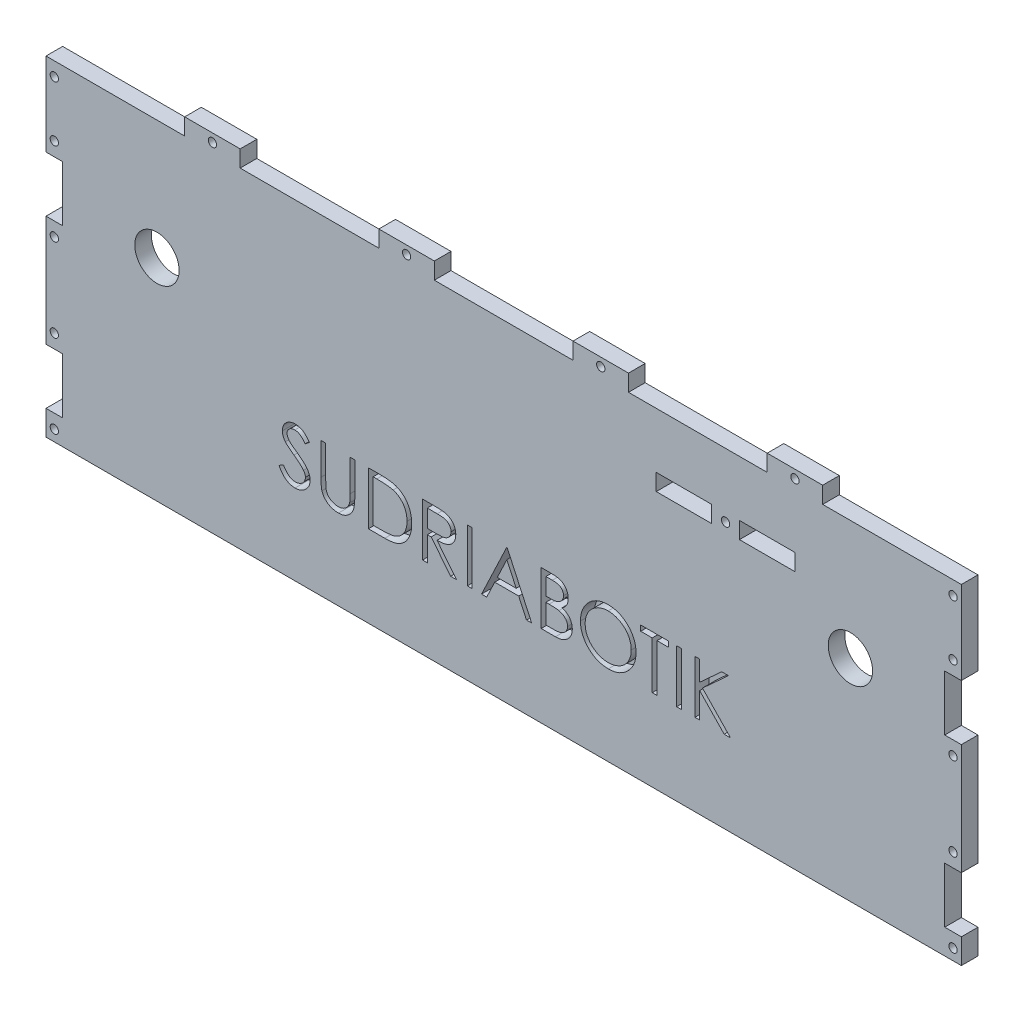
from build123d import *

# Parameters (mm, degrees)
ESQUISSE1_W             = 330
ESQUISSE1_H             = 238
ESQUISSE1_R             = 8
ESQUISSE1_W_2           = 15
ESQUISSE1_H_2           = 6
ESQUISSE1_W_3           = 20
BOSS_EXTRU_1_DEPTH      = 6
ESQUISSE2_W             = 20
ESQUISSE2_H             = 6
BOSS_EXTRU_2_DEPTH      = 6
ESQUISSE3_W             = 6
ESQUISSE3_H             = 20
ESQUISSE3_W_2           = 12
ESQUISSE3_H_2           = 10
ENL_V_MAT_EXTRU_1_DEPTH = 6
ESQUISSE4_R             = 1.5
ENL_V_MAT_EXTRU_2_DEPTH = 6
ESQUISSE5_W             = 423.604058921
ESQUISSE5_H             = 150.356061945
ENL_V_MAT_EXTRU_3_DEPTH = 6
ESQUISSE6_W             = 1.709615384
ESQUISSE6_H             = 19.05
ESQUISSE6_W_2           = 1.709615385
ENL_V_MAT_EXTRU_4_DEPTH = 5


with BuildPart() as part:
    # Esquisse1 → Boss.-Extru.1 (new body)
    with BuildSketch(Plane.XY):
        Rectangle(ESQUISSE1_W, ESQUISSE1_H)
        with Locations((-125, 76)):
            Circle(ESQUISSE1_R, mode=Mode.SUBTRACT)
        with Locations((125, 76)):
            Circle(ESQUISSE1_R, mode=Mode.SUBTRACT)
        with Locations((-85, -58)):
            Rectangle(ESQUISSE1_W_2, ESQUISSE1_H_2, mode=Mode.SUBTRACT)
        with Locations((0, -58)):
            Rectangle(ESQUISSE1_W_2, ESQUISSE1_H_2, mode=Mode.SUBTRACT)
        with Locations((85, -58)):
            Rectangle(ESQUISSE1_W_2, ESQUISSE1_H_2, mode=Mode.SUBTRACT)
        with Locations((65, 96)):
            Rectangle(ESQUISSE1_W_3, ESQUISSE1_H_2, mode=Mode.SUBTRACT)
        with Locations((95, 96)):
            Rectangle(ESQUISSE1_W_3, ESQUISSE1_H_2, mode=Mode.SUBTRACT)
    extrude(amount=BOSS_EXTRU_1_DEPTH)

    # Esquisse2 → Boss.-Extru.2 (add)
    with BuildSketch(Plane.XY.offset(6)):
        with Locations((-105, 122)):
            Rectangle(ESQUISSE2_W, ESQUISSE2_H)
        with Locations((-35, 122)):
            Rectangle(ESQUISSE2_W, ESQUISSE2_H)
        with Locations((35, 122)):
            Rectangle(ESQUISSE2_W, ESQUISSE2_H)
        with Locations((105, 122)):
            Rectangle(ESQUISSE2_W, ESQUISSE2_H)
        with Locations((105, -122)):
            Rectangle(ESQUISSE2_W, ESQUISSE2_H)
        with Locations((35, -122)):
            Rectangle(ESQUISSE2_W, ESQUISSE2_H)
        with Locations((-35, -122)):
            Rectangle(ESQUISSE2_W, ESQUISSE2_H)
        with Locations((-105, -122)):
            Rectangle(ESQUISSE2_W, ESQUISSE2_H)
    extrude(amount=-BOSS_EXTRU_2_DEPTH)

    # Esquisse3 → Enlèv. mat.-Extru.1 (cut)
    with BuildSketch(Plane.XY.offset(6)):
        with Locations((-162, 79)):
            Rectangle(ESQUISSE3_W, ESQUISSE3_H)
        with Locations((-162, 19)):
            Rectangle(ESQUISSE3_W, ESQUISSE3_H)
        with Locations((-162, -19)):
            Rectangle(ESQUISSE3_W, ESQUISSE3_H)
        with Locations((-162, -79)):
            Rectangle(ESQUISSE3_W, ESQUISSE3_H)
        with Locations((162, -79)):
            Rectangle(ESQUISSE3_W, ESQUISSE3_H)
        with Locations((162, -19)):
            Rectangle(ESQUISSE3_W, ESQUISSE3_H)
        with Locations((162, 19)):
            Rectangle(ESQUISSE3_W, ESQUISSE3_H)
        with Locations((162, 79)):
            Rectangle(ESQUISSE3_W, ESQUISSE3_H)
        with Locations((159, -114)):
            Rectangle(ESQUISSE3_W_2, ESQUISSE3_H_2)
        with Locations((-159, -114)):
            Rectangle(ESQUISSE3_W_2, ESQUISSE3_H_2)
    extrude(amount=-ENL_V_MAT_EXTRU_1_DEPTH, mode=Mode.SUBTRACT)

    # Esquisse4 → Enlèv. mat.-Extru.2 (cut)
    with BuildSketch(Plane.XY.offset(6)):
        with Locations((-162, 114)):
            Circle(ESQUISSE4_R)
        with Locations((-162, 94)):
            Circle(ESQUISSE4_R)
        with Locations((-162, 64)):
            Circle(ESQUISSE4_R)
        with Locations((-162, 34)):
            Circle(ESQUISSE4_R)
        with Locations((-162, 4)):
            Circle(ESQUISSE4_R)
        with Locations((-105, 122)):
            Circle(ESQUISSE4_R)
        with Locations((-162, -4)):
            Circle(ESQUISSE4_R)
        with Locations((-162, -34)):
            Circle(ESQUISSE4_R)
        with Locations((-162, -64)):
            Circle(ESQUISSE4_R)
        with Locations((-162, -94)):
            Circle(ESQUISSE4_R)
        with Locations((-97.5, -58)):
            Circle(ESQUISSE4_R)
        with Locations((-72.5, -58)):
            Circle(ESQUISSE4_R)
        with Locations((162, -94)):
            Circle(ESQUISSE4_R)
        with Locations((162, -64)):
            Circle(ESQUISSE4_R)
        with Locations((162, -34)):
            Circle(ESQUISSE4_R)
        with Locations((162, -4)):
            Circle(ESQUISSE4_R)
        with Locations((80, 96)):
            Circle(ESQUISSE4_R)
        with Locations((162, 4)):
            Circle(ESQUISSE4_R)
        with Locations((162, 34)):
            Circle(ESQUISSE4_R)
        with Locations((162, 64)):
            Circle(ESQUISSE4_R)
        with Locations((162, 94)):
            Circle(ESQUISSE4_R)
        with Locations((162, 114)):
            Circle(ESQUISSE4_R)
        with Locations((-12.5, -58)):
            Circle(ESQUISSE4_R)
        with Locations((12.5, -58)):
            Circle(ESQUISSE4_R)
        with Locations((72.5, -58)):
            Circle(ESQUISSE4_R)
        with Locations((97.5, -58)):
            Circle(ESQUISSE4_R)
        with Locations((-35, 122)):
            Circle(ESQUISSE4_R)
        with Locations((35, 122)):
            Circle(ESQUISSE4_R)
        with Locations((105, 122)):
            Circle(ESQUISSE4_R)
    extrude(amount=-ENL_V_MAT_EXTRU_2_DEPTH, mode=Mode.SUBTRACT)

    # Esquisse5 → Enlèv. mat.-Extru.3 (cut)
    with BuildSketch(Plane.XY.offset(6)):
        with Locations((11.705214191, -75.178030973)):
            Rectangle(ESQUISSE5_W, ESQUISSE5_H)
    extrude(amount=-ENL_V_MAT_EXTRU_3_DEPTH, mode=Mode.SUBTRACT)

    # Esquisse6 → Enlèv. mat.-Extru.4 (cut)
    with BuildSketch(Plane.XY.offset(6)):
        with BuildLine():
            Line((-81.011538462, 33.174909856), (-79.401141827, 34.140384615))
            add(Edge.make_bspline(
                [(-79.401141827, 34.140384615), (-79.251363993, 33.889662749), (-78.964395442, 33.409289328), (-78.485688759, 32.760184851), (-77.989665343, 32.208485112), (-77.47265197, 31.757399576), (-76.937804452, 31.402259207), (-76.381631246, 31.15078706), (-75.80600659, 30.993945823), (-75.414263362, 30.974895352), (-75.218689904, 30.965384615)],
                knots=[0, 0, 0, 0, 0.000875761, 0.001677924, 0.002415421, 0.003097148, 0.00373115, 0.004334059, 0.004921814, 0.005507782, 0.005507782, 0.005507782, 0.005507782], degree=3))
            add(Edge.make_bspline(
                [(-75.218689904, 30.965384615), (-75.051665706, 30.970036476), (-74.720539841, 30.9792588), (-74.233065347, 31.06787288), (-73.759635824, 31.204010324), (-73.31000881, 31.398978537), (-72.890388393, 31.634863724), (-72.522414809, 31.91977649), (-72.204300964, 32.238761695), (-71.944082784, 32.594630144), (-71.744438591, 32.977356339), (-71.59099319, 33.370199731), (-71.50583929, 33.77933151), (-71.493011817, 34.054797029), (-71.486538462, 34.193810096)],
                knots=[0, 0, 0, 0, 0.000500623, 0.000992486, 0.001481559, 0.001975623, 0.002459366, 0.002921918, 0.003367162, 0.003806809, 0.004238704, 0.004658996, 0.005068388, 0.005485462, 0.005485462, 0.005485462, 0.005485462], degree=3))
            add(Edge.make_bspline(
                [(-71.486538462, 34.193810096), (-71.494562924, 34.352419578), (-71.510875484, 34.674849478), (-71.648751111, 35.150553303), (-71.865644869, 35.621320006), (-72.065738687, 35.912519751), (-72.169621394, 36.063701923)],
                knots=[0, 0, 0, 0, 0.000475055, 0.000965718, 0.001474521, 0.002023895, 0.002023895, 0.002023895, 0.002023895], degree=3))
            add(Edge.make_bspline(
                [(-72.169621394, 36.063701923), (-72.254914309, 36.17281392), (-72.433976113, 36.401880909), (-72.741810575, 36.742849977), (-73.103031854, 37.0945588), (-73.505278346, 37.470437381), (-73.963202729, 37.853003818), (-74.462462486, 38.260501159), (-75.015804347, 38.6774326), (-75.403877322, 38.957046135), (-75.604116587, 39.101322115)],
                knots=[0, 0, 0, 0, 0.000415395, 0.00087207, 0.001376677, 0.001927572, 0.002523203, 0.00316627, 0.003860812, 0.004601225, 0.004601225, 0.004601225, 0.004601225], degree=3))
            add(Edge.make_bspline(
                [(-75.604116587, 39.101322115), (-75.804544337, 39.244080571), (-76.187746934, 39.517023867), (-76.723642932, 39.922104613), (-77.202856367, 40.292457674), (-77.623257299, 40.631569511), (-77.984660819, 40.939486117), (-78.289914814, 41.213250614), (-78.531243246, 41.460266853), (-78.665440049, 41.62051187), (-78.725691106, 41.692457933)],
                knots=[0, 0, 0, 0, 0.000738177, 0.001411339, 0.002015128, 0.00255509, 0.003031508, 0.003439403, 0.00378484, 0.004066302, 0.004066302, 0.004066302, 0.004066302], degree=3))
            add(Edge.make_bspline(
                [(-78.725691106, 41.692457933), (-78.809905959, 41.804586433), (-78.97552577, 42.025102178), (-79.1941436, 42.369770333), (-79.379958186, 42.722594106), (-79.525621737, 43.084521597), (-79.648283157, 43.45047171), (-79.730785608, 43.825219204), (-79.782445925, 44.207082542), (-79.787736309, 44.464058881), (-79.790384615, 44.592698317)],
                knots=[0, 0, 0, 0, 0.000420569, 0.000827105, 0.001223098, 0.001614988, 0.001996332, 0.002379618, 0.002764439, 0.003150168, 0.003150168, 0.003150168, 0.003150168], degree=3))
            add(Edge.make_bspline(
                [(-79.790384615, 44.592698317), (-79.783280549, 44.79424609), (-79.769224262, 45.193033694), (-79.650349446, 45.775587214), (-79.462718411, 46.331773285), (-79.199856235, 46.85608553), (-78.860998357, 47.334871798), (-78.468862411, 47.773639491), (-78.00180275, 48.142494203), (-77.489343472, 48.464776978), (-76.928422361, 48.717031228), (-76.340643301, 48.907318848), (-75.725072095, 49.015137808), (-75.308132177, 49.030610571), (-75.096574519, 49.038461538)],
                knots=[0, 0, 0, 0, 0.000604151, 0.001195389, 0.001775851, 0.002361222, 0.002947712, 0.003531189, 0.004120021, 0.004726782, 0.005343269, 0.00595998, 0.006576078, 0.0072107, 0.0072107, 0.0072107, 0.0072107], degree=3))
            add(Edge.make_bspline(
                [(-75.096574519, 49.038461538), (-74.872088773, 49.030718793), (-74.425658273, 49.015320944), (-73.768981828, 48.881440095), (-73.136735643, 48.659912153), (-72.628137302, 48.408513886), (-72.230086129, 48.157427181), (-71.926523112, 47.92871928), (-71.618906702, 47.665420475), (-71.304755575, 47.366829435), (-70.989392843, 47.030206404), (-70.668136624, 46.657856798), (-70.340235675, 46.252056115), (-70.129293065, 45.962362761), (-70.021153846, 45.813852163)],
                knots=[0, 0, 0, 0, 0.000672945, 0.001338273, 0.002000837, 0.002678365, 0.003035146, 0.003411415, 0.003817467, 0.004249345, 0.004710968, 0.005200635, 0.005724499, 0.006275553, 0.006275553, 0.006275553, 0.006275553], degree=3))
            Line((-70.021153846, 45.813852163), (-71.566676683, 44.642307692))
            add(Edge.make_bspline(
                [(-71.566676683, 44.642307692), (-71.659999544, 44.762533279), (-71.839717554, 44.994059648), (-72.11256519, 45.318297809), (-72.369732831, 45.614478933), (-72.623100007, 45.871736273), (-72.859285344, 46.104157885), (-73.088522388, 46.303147418), (-73.307512214, 46.470654588), (-73.583557113, 46.649417392), (-73.930363552, 46.82661779), (-74.365707956, 46.976563487), (-74.82065611, 47.066670324), (-75.130515962, 47.078584126), (-75.287379808, 47.084615385)],
                knots=[0, 0, 0, 0, 0.000456531, 0.000879173, 0.001271193, 0.001632818, 0.001962066, 0.002265056, 0.002542873, 0.002788442, 0.003250947, 0.003707127, 0.004165902, 0.004636274, 0.004636274, 0.004636274, 0.004636274], degree=3))
            add(Edge.make_bspline(
                [(-75.287379808, 47.084615385), (-75.484174594, 47.078020275), (-75.863674801, 47.065302227), (-76.402464514, 46.926400593), (-76.887390021, 46.707696467), (-77.304054696, 46.401182087), (-77.650965957, 46.038029255), (-77.901911383, 45.620132915), (-78.052951564, 45.15867441), (-78.0713826, 44.836774823), (-78.080769231, 44.672836538)],
                knots=[0, 0, 0, 0, 0.000589178, 0.001136173, 0.001656971, 0.002176017, 0.002678179, 0.00315397, 0.003627044, 0.004118018, 0.004118018, 0.004118018, 0.004118018], degree=3))
            add(Edge.make_bspline(
                [(-78.080769231, 44.672836538), (-78.078629499, 44.57077492), (-78.074346536, 44.366484791), (-78.01461228, 44.064670623), (-77.937871646, 43.763618904), (-77.816263893, 43.464683132), (-77.648377312, 43.162635263), (-77.427913426, 42.852274092), (-77.150255256, 42.530864077), (-76.937564661, 42.321818229), (-76.825270433, 42.211448317)],
                knots=[0, 0, 0, 0, 0.00030567, 0.000611839, 0.000920095, 0.001236855, 0.001576745, 0.001954713, 0.002376906, 0.002849133, 0.002849133, 0.002849133, 0.002849133], degree=3))
            add(Edge.make_bspline(
                [(-76.825270433, 42.211448317), (-76.783570677, 42.174235363), (-76.684501603, 42.0858259), (-76.503385493, 41.941087915), (-76.26421112, 41.762547112), (-75.973223996, 41.541636147), (-75.625058785, 41.285378474), (-75.2196772, 40.997050671), (-74.761598, 40.667292672), (-74.436540144, 40.43674663), (-74.264663462, 40.31484375)],
                knots=[0, 0, 0, 0, 0.000167648, 0.000398294, 0.000695191, 0.001063064, 0.001494301, 0.001992036, 0.002555426, 0.003187576, 0.003187576, 0.003187576, 0.003187576], degree=3))
            add(Edge.make_bspline(
                [(-74.264663462, 40.31484375), (-74.057911562, 40.164395779), (-73.657565164, 39.873074134), (-73.087928907, 39.435383076), (-72.571435466, 39.007314507), (-72.106271458, 38.591602102), (-71.687841428, 38.191399196), (-71.320787548, 37.801891029), (-71.001369774, 37.425868126), (-70.657494313, 36.94378025), (-70.306115324, 36.351700348), (-70.004355119, 35.626285936), (-69.814081828, 34.898051677), (-69.789199723, 34.408592753), (-69.776923077, 34.167097356)],
                knots=[0, 0, 0, 0, 0.000767075, 0.001485335, 0.002154722, 0.002779037, 0.003356594, 0.003891122, 0.004384123, 0.00483528, 0.005666491, 0.006443216, 0.007186426, 0.00791025, 0.00791025, 0.00791025, 0.00791025], degree=3))
            add(Edge.make_bspline(
                [(-69.776923077, 34.167097356), (-69.780499786, 33.996309397), (-69.787583746, 33.658050067), (-69.869013863, 33.16136172), (-69.988319469, 32.678956558), (-70.168136414, 32.216797503), (-70.387609604, 31.76642958), (-70.666100181, 31.339666579), (-70.988903437, 30.927063181), (-71.3592015, 30.539621607), (-71.764399911, 30.183951597), (-72.192664021, 29.86756342), (-72.644694792, 29.60375726), (-73.11804003, 29.388487677), (-73.612808463, 29.22012096), (-74.128833686, 29.098130915), (-74.666966312, 29.023260545), (-75.032728933, 29.015489444), (-75.218689904, 29.011538462)],
                knots=[0, 0, 0, 0, 0.000511871, 0.001013801, 0.001506197, 0.002000187, 0.002498522, 0.003006623, 0.003525739, 0.004068285, 0.004611795, 0.005141506, 0.005663141, 0.00617888, 0.006699006, 0.007228455, 0.007767608, 0.008325229, 0.008325229, 0.008325229, 0.008325229], degree=3))
            add(Edge.make_bspline(
                [(-75.218689904, 29.011538462), (-75.362573699, 29.01432075), (-75.648529222, 29.019850287), (-76.07149083, 29.068734113), (-76.485907737, 29.137897063), (-76.886579758, 29.247701643), (-77.278669098, 29.380926333), (-77.660470475, 29.544964972), (-78.032168925, 29.741545739), (-78.395847483, 29.966308659), (-78.750581205, 30.227880098), (-79.093042881, 30.532535842), (-79.434468876, 30.87187352), (-79.764781705, 31.255108157), (-80.090662676, 31.676048294), (-80.40568659, 32.138632278), (-80.716374225, 32.640340446), (-80.9113127, 32.993391841), (-81.011538462, 33.174909856)],
                knots=[0, 0, 0, 0, 0.00043149, 0.000857546, 0.001276015, 0.001690708, 0.002102228, 0.002517623, 0.002935831, 0.003362587, 0.00379916, 0.004256154, 0.004736468, 0.005242286, 0.005772779, 0.00633272, 0.006920475, 0.007542442, 0.007542442, 0.007542442, 0.007542442], degree=3))
        make_face()
        with BuildLine():
            Line((-65.869230769, 48.55), (-64.159615385, 48.55))
            Line((-64.159615385, 48.55), (-64.159615385, 37.136027644))
            add(Edge.make_bspline(
                [(-64.159615385, 37.136027644), (-64.159869805, 36.97447964), (-64.160352613, 36.667914462), (-64.157127644, 36.231569854), (-64.148095939, 35.843644041), (-64.142401842, 35.502641707), (-64.129734498, 35.21012761), (-64.1194037, 34.96451699), (-64.106120098, 34.766972831), (-64.090155559, 34.651688077), (-64.083293269, 34.602133413)],
                knots=[0, 0, 0, 0, 0.000484645, 0.000919698, 0.001309016, 0.001648735, 0.001942798, 0.002187297, 0.002386321, 0.002536367, 0.002536367, 0.002536367, 0.002536367], degree=3))
            add(Edge.make_bspline(
                [(-64.083293269, 34.602133413), (-64.055113101, 34.423353173), (-64.000340615, 34.075866319), (-63.860751044, 33.581065527), (-63.665801503, 33.135124305), (-63.434790085, 32.724127134), (-63.130356872, 32.359513618), (-62.765666201, 32.023625907), (-62.323827204, 31.729865085), (-61.832551622, 31.461255666), (-61.303041972, 31.245364289), (-60.761960651, 31.082114692), (-60.217441007, 30.982625252), (-59.852899308, 30.971105233), (-59.671875, 30.965384615)],
                knots=[0, 0, 0, 0, 0.000542706, 0.001054833, 0.001536872, 0.002000273, 0.002463973, 0.002955555, 0.003482676, 0.004051288, 0.004633103, 0.005194538, 0.005744759, 0.006287505, 0.006287505, 0.006287505, 0.006287505], degree=3))
            add(Edge.make_bspline(
                [(-59.671875, 30.965384615), (-59.51646107, 30.971229429), (-59.20653084, 30.982885298), (-58.746030125, 31.055065373), (-58.297538105, 31.185152738), (-57.858840118, 31.353009137), (-57.447626903, 31.574792454), (-57.063669026, 31.830992309), (-56.720965327, 32.13149722), (-56.408229653, 32.464057667), (-56.135896645, 32.839287149), (-55.899833717, 33.249015301), (-55.706471157, 33.699408174), (-55.610984258, 34.015934387), (-55.561929087, 34.178545673)],
                knots=[0, 0, 0, 0, 0.000466331, 0.000929968, 0.001393872, 0.001865126, 0.002336303, 0.002792484, 0.003246969, 0.003700588, 0.004159315, 0.004634539, 0.005116578, 0.005625853, 0.005625853, 0.005625853, 0.005625853], degree=3))
            add(Edge.make_bspline(
                [(-55.561929087, 34.178545673), (-55.545599833, 34.245757199), (-55.509211676, 34.395531565), (-55.475209903, 34.648740304), (-55.439795814, 34.947495271), (-55.415223655, 35.293942995), (-55.391268441, 35.686922574), (-55.376937002, 36.128481204), (-55.370312865, 36.617015519), (-55.368338848, 36.957940643), (-55.367307692, 37.136027644)],
                knots=[0, 0, 0, 0, 0.000207373, 0.000462111, 0.000765533, 0.00111002, 0.001503745, 0.001946676, 0.002435197, 0.002969466, 0.002969466, 0.002969466, 0.002969466], degree=3))
            Line((-55.367307692, 37.136027644), (-55.367307692, 48.55))
            Line((-55.367307692, 48.55), (-53.657692308, 48.55))
            Line((-53.657692308, 48.55), (-53.657692308, 37.044441106))
            add(Edge.make_bspline(
                [(-53.657692308, 37.044441106), (-53.659075449, 36.837077072), (-53.661774732, 36.432393552), (-53.685182156, 35.839386869), (-53.722503826, 35.276851356), (-53.775234705, 34.744711397), (-53.84510468, 34.244871187), (-53.922802666, 33.77294952), (-54.021751267, 33.332333946), (-54.137321636, 32.91958893), (-54.269439091, 32.526693493), (-54.440568769, 32.15381089), (-54.633379262, 31.789605372), (-54.862059016, 31.439585522), (-55.119023827, 31.102201569), (-55.409953689, 30.779499603), (-55.725226622, 30.466322794), (-56.070083654, 30.170704534), (-56.438840084, 29.899603022), (-56.830398996, 29.66121801), (-57.241752557, 29.45970375), (-57.671831487, 29.293827647), (-58.12081932, 29.169106757), (-58.588727377, 29.076169123), (-59.076620701, 29.023360904), (-59.408442616, 29.015512684), (-59.576472356, 29.011538462)],
                knots=[0, 0, 0, 0, 0.000622072, 0.001214011, 0.001780083, 0.002313205, 0.002817812, 0.003293985, 0.003747637, 0.004171705, 0.004579618, 0.004989561, 0.005401029, 0.005814896, 0.006242317, 0.006672048, 0.007117291, 0.007574667, 0.008033394, 0.008488904, 0.008947996, 0.009405817, 0.009869721, 0.010344209, 0.010835584, 0.011339671, 0.011339671, 0.011339671, 0.011339671], degree=3))
            add(Edge.make_bspline(
                [(-59.576472356, 29.011538462), (-59.759728471, 29.015809827), (-60.119276315, 29.02419023), (-60.649073509, 29.072211199), (-61.156969349, 29.162662745), (-61.648328051, 29.277833296), (-62.116460014, 29.436676209), (-62.56763719, 29.622267431), (-62.994132297, 29.850199376), (-63.402864355, 30.103800558), (-63.782910527, 30.389140375), (-64.131783536, 30.700146179), (-64.450059346, 31.031835947), (-64.73237325, 31.387800795), (-64.983402636, 31.765272229), (-65.199648512, 32.165318091), (-65.385322026, 32.587783498), (-65.481152056, 32.88144306), (-65.529597356, 33.029897837)],
                knots=[0, 0, 0, 0, 0.00054985, 0.001078804, 0.00159388, 0.002096463, 0.002591234, 0.003075293, 0.003558373, 0.00404014, 0.004517154, 0.004982061, 0.005440915, 0.005894454, 0.006343216, 0.006799141, 0.007257137, 0.007725384, 0.007725384, 0.007725384, 0.007725384], degree=3))
            add(Edge.make_bspline(
                [(-65.529597356, 33.029897837), (-65.557775888, 33.131312277), (-65.618895752, 33.351282458), (-65.68434773, 33.71533606), (-65.739370017, 34.134517255), (-65.791107412, 34.608854735), (-65.821636169, 35.138716152), (-65.848401085, 35.723871822), (-65.869419325, 36.3650293), (-65.869295378, 36.811640306), (-65.869230769, 37.044441106)],
                knots=[0, 0, 0, 0, 0.000315631, 0.000684612, 0.001108268, 0.001584059, 0.002115608, 0.002700083, 0.003341473, 0.00403983, 0.00403983, 0.00403983, 0.00403983], degree=3))
            Line((-65.869230769, 37.044441106), (-65.869230769, 48.55))
        make_face()
        with BuildLine():
            Line((-48.773076923, 29.5), (-48.773076923, 48.55))
            Line((-48.773076923, 48.55), (-44.926442308, 48.55))
            add(Edge.make_bspline(
                [(-44.926442308, 48.55), (-44.591875386, 48.547591155), (-43.945493835, 48.542937278), (-43.0114318, 48.513429421), (-42.147194464, 48.461229885), (-41.355624188, 48.38519575), (-40.634547877, 48.291834239), (-39.985984596, 48.174810609), (-39.406580789, 48.036626425), (-39.050239977, 47.918813331), (-38.881730769, 47.863100962)],
                knots=[0, 0, 0, 0, 0.001003701, 0.001939145, 0.002803238, 0.003600649, 0.004324393, 0.004983829, 0.005577107, 0.006109355, 0.006109355, 0.006109355, 0.006109355], degree=3))
            add(Edge.make_bspline(
                [(-38.881730769, 47.863100962), (-38.661323688, 47.779113835), (-38.225507627, 47.613044132), (-37.604983146, 47.299773406), (-37.020826527, 46.944827809), (-36.469905182, 46.547739471), (-35.964803541, 46.097264945), (-35.485789132, 45.612539951), (-35.052457563, 45.075937699), (-34.655628124, 44.498586693), (-34.29783832, 43.887288237), (-33.986838047, 43.243207146), (-33.72855274, 42.569614342), (-33.514141035, 41.868383036), (-33.345159602, 41.137971323), (-33.229869374, 40.377528709), (-33.153827272, 39.59006055), (-33.146185221, 39.055710968), (-33.142307692, 38.784585337)],
                knots=[0, 0, 0, 0, 0.000707216, 0.001398395, 0.002081659, 0.00275642, 0.003432398, 0.004109744, 0.004798717, 0.005498398, 0.006209843, 0.006921575, 0.007641596, 0.00837191, 0.009119876, 0.00988844, 0.010677895, 0.011491048, 0.011491048, 0.011491048, 0.011491048], degree=3))
            add(Edge.make_bspline(
                [(-33.142307692, 38.784585337), (-33.145731072, 38.549120596), (-33.152477201, 38.08511273), (-33.213052477, 37.401267284), (-33.301097876, 36.737709131), (-33.437409867, 36.097598107), (-33.602886405, 35.47532595), (-33.814962714, 34.877524734), (-34.057907343, 34.298710572), (-34.341207396, 33.746709738), (-34.652219792, 33.223741669), (-34.98598528, 32.730752009), (-35.342147865, 32.274775444), (-35.72410381, 31.854431142), (-36.126917238, 31.470352779), (-36.55322538, 31.119331953), (-37.00412827, 30.80823699), (-37.477606347, 30.524843158), (-37.987472136, 30.277626652), (-38.543383065, 30.068457598), (-39.147709905, 29.895121021), (-39.798969299, 29.750499431), (-40.498286514, 29.635778683), (-41.246347171, 29.558890747), (-42.042001933, 29.506895499), (-42.588351934, 29.50234313), (-42.869561298, 29.5)],
                knots=[0, 0, 0, 0, 0.000706237, 0.001391714, 0.002058223, 0.002713094, 0.0033537, 0.003988529, 0.004614381, 0.00523561, 0.005848187, 0.006438797, 0.007020499, 0.007582414, 0.008141144, 0.008688885, 0.009237237, 0.00978306, 0.010342871, 0.010934675, 0.011562654, 0.012227402, 0.012935071, 0.013687308, 0.014482607, 0.015326104, 0.015326104, 0.015326104, 0.015326104], degree=3))
            Line((-42.869561298, 29.5), (-48.773076923, 29.5))
        make_face()
        with BuildLine():
            Line((-47.063461538, 31.453846154), (-44.876832933, 31.453846154))
            add(Edge.make_bspline(
                [(-44.876832933, 31.453846154), (-44.562625658, 31.455196507), (-43.958289998, 31.457793731), (-43.089294327, 31.480584079), (-42.295293612, 31.517823767), (-41.576175111, 31.569939548), (-40.93234485, 31.638893011), (-40.362457297, 31.715772839), (-39.868380534, 31.811553249), (-39.569407455, 31.898372042), (-39.43125, 31.938491587)],
                knots=[0, 0, 0, 0, 0.000942609, 0.001812982, 0.002607649, 0.003327064, 0.003975633, 0.004549852, 0.005052029, 0.005483452, 0.005483452, 0.005483452, 0.005483452], degree=3))
            add(Edge.make_bspline(
                [(-39.43125, 31.938491587), (-39.257359629, 31.999732211), (-38.913732256, 32.120750728), (-38.419079492, 32.341500284), (-37.957759224, 32.602986406), (-37.5217318, 32.893647355), (-37.117182433, 33.22373488), (-36.739316886, 33.586071262), (-36.388895938, 33.982500538), (-36.069540062, 34.412530674), (-35.783744864, 34.873485133), (-35.536251458, 35.360832214), (-35.319345265, 35.869232138), (-35.149100354, 36.406491987), (-35.015665531, 36.967808719), (-34.921152016, 37.553221823), (-34.862289015, 38.162621971), (-34.855423134, 38.577107105), (-34.851923077, 38.788401442)],
                knots=[0, 0, 0, 0, 0.000552954, 0.0010927, 0.001622369, 0.002142047, 0.002662942, 0.003186541, 0.00371103, 0.004248343, 0.004791599, 0.005336033, 0.00588673, 0.006447905, 0.007024554, 0.007616161, 0.008225616, 0.008859377, 0.008859377, 0.008859377, 0.008859377], degree=3))
            add(Edge.make_bspline(
                [(-34.851923077, 38.788401442), (-34.854716827, 39.011196528), (-34.860205173, 39.448879446), (-34.929189634, 40.091085944), (-35.029999815, 40.708744914), (-35.175779591, 41.301897663), (-35.361549089, 41.871701408), (-35.593385639, 42.415004742), (-35.858271096, 42.937545529), (-36.173430686, 43.427263148), (-36.518592701, 43.890412785), (-36.901649445, 44.314710254), (-37.316515112, 44.701122088), (-37.758664792, 45.055666061), (-38.240559575, 45.364078354), (-38.750847521, 45.639958718), (-39.297014674, 45.87408807), (-39.676995204, 45.998614451), (-39.870102163, 46.061899038)],
                knots=[0, 0, 0, 0, 0.000668091, 0.001312471, 0.001935443, 0.002544456, 0.003143013, 0.003731288, 0.00431499, 0.004898305, 0.005476064, 0.006046199, 0.006610479, 0.007175469, 0.007743877, 0.008324376, 0.008914147, 0.00952359, 0.00952359, 0.00952359, 0.00952359], degree=3))
            add(Edge.make_bspline(
                [(-39.870102163, 46.061899038), (-40.02985626, 46.106075596), (-40.369537302, 46.200007078), (-40.923834956, 46.302470891), (-41.54766884, 46.392846807), (-42.243808642, 46.469362707), (-43.011460827, 46.524266556), (-43.851215786, 46.56547614), (-44.763436491, 46.593270811), (-45.395801425, 46.595168774), (-45.724008413, 46.596153846)],
                knots=[0, 0, 0, 0, 0.000497047, 0.001056858, 0.001689365, 0.002388077, 0.003157248, 0.00399784, 0.00491028, 0.005894865, 0.005894865, 0.005894865, 0.005894865], degree=3))
            Line((-45.724008413, 46.596153846), (-47.063461538, 46.596153846))
            Line((-47.063461538, 46.596153846), (-47.063461538, 31.453846154))
        make_face(mode=Mode.SUBTRACT)
        with BuildLine():
            Line((-29.234615385, 48.55), (-25.422325721, 48.55))
            add(Edge.make_bspline(
                [(-25.422325721, 48.55), (-25.167920436, 48.549153168), (-24.679434107, 48.547527156), (-23.979628164, 48.538460646), (-23.343754965, 48.51247451), (-22.772146982, 48.490112077), (-22.264814703, 48.449334511), (-21.820202449, 48.410360132), (-21.440357981, 48.359340635), (-21.210419848, 48.311958262), (-21.106310096, 48.290504808)],
                knots=[0, 0, 0, 0, 0.000763231, 0.001465487, 0.002099375, 0.002672414, 0.003181388, 0.003626042, 0.004011375, 0.004330196, 0.004330196, 0.004330196, 0.004330196], degree=3))
            add(Edge.make_bspline(
                [(-21.106310096, 48.290504808), (-20.966936899, 48.256069128), (-20.691163714, 48.187932374), (-20.294106925, 48.043916547), (-19.915750391, 47.877258304), (-19.557665776, 47.681512912), (-19.221646684, 47.455227326), (-18.904228449, 47.202307973), (-18.603970713, 46.924138753), (-18.333016411, 46.613706259), (-18.077533858, 46.288024685), (-17.86205862, 45.93585138), (-17.676313066, 45.567579351), (-17.528427824, 45.179463263), (-17.409349139, 44.775267048), (-17.325386322, 44.351329454), (-17.27503343, 43.909581861), (-17.269907044, 43.608276672), (-17.267307692, 43.455498798)],
                knots=[0, 0, 0, 0, 0.000430426, 0.000851669, 0.001265096, 0.001669855, 0.002074164, 0.002478834, 0.002886515, 0.003300082, 0.003713774, 0.004126778, 0.004536365, 0.004949528, 0.005370979, 0.005799064, 0.006244503, 0.00670269, 0.00670269, 0.00670269, 0.00670269], degree=3))
            add(Edge.make_bspline(
                [(-17.267307692, 43.455498798), (-17.275303239, 43.201670586), (-17.290904622, 42.706386001), (-17.436365543, 41.987597489), (-17.674634887, 41.317095648), (-18.002965931, 40.695724719), (-18.421083363, 40.135596777), (-18.923594012, 39.643614442), (-19.510778211, 39.231917204), (-20.057400631, 38.946424081), (-20.540259347, 38.763582678), (-20.937769235, 38.634933354), (-21.371385212, 38.535536085), (-21.836952705, 38.446490225), (-22.336409173, 38.379261717), (-22.86855753, 38.330022396), (-23.433777298, 38.299248217), (-23.822065661, 38.294665304), (-24.021814904, 38.292307692)],
                knots=[0, 0, 0, 0, 0.000760784, 0.001484488, 0.002189383, 0.002889303, 0.0035846, 0.004278134, 0.004989692, 0.005728727, 0.006121341, 0.006537716, 0.006981075, 0.007454841, 0.007959448, 0.008492202, 0.00905781, 0.009657048, 0.009657048, 0.009657048, 0.009657048], degree=3))
            Line((-24.021814904, 38.292307692), (-17.023076923, 29.5))
            Line((-17.023076923, 29.5), (-19.137199519, 29.5))
            Line((-19.137199519, 29.5), (-26.1359375, 38.292307692))
            Line((-26.1359375, 38.292307692), (-27.525, 38.292307692))
            Line((-27.525, 38.292307692), (-27.525, 29.5))
            Line((-27.525, 29.5), (-29.234615385, 29.5))
            Line((-29.234615385, 29.5), (-29.234615385, 48.55))
        make_face()
        with BuildLine():
            Line((-27.525, 46.596153846), (-27.525, 40.246153846))
            Line((-27.525, 40.246153846), (-24.037079327, 40.219441106))
            add(Edge.make_bspline(
                [(-24.037079327, 40.219441106), (-23.874228829, 40.219369061), (-23.558578183, 40.219229416), (-23.10191885, 40.24096697), (-22.676722242, 40.265695602), (-22.28461472, 40.303519897), (-21.925421117, 40.352266516), (-21.599320968, 40.413242759), (-21.305781957, 40.484283271), (-20.963434197, 40.594237835), (-20.581146791, 40.76844202), (-20.165685559, 41.021891377), (-19.811887121, 41.340674726), (-19.512977042, 41.705201679), (-19.272786851, 42.105993262), (-19.103448384, 42.538245214), (-18.99599309, 42.991045198), (-18.98331915, 43.302257471), (-18.976923077, 43.459314904)],
                knots=[0, 0, 0, 0, 0.000488476, 0.000946806, 0.001371236, 0.001766143, 0.002128271, 0.002458336, 0.00276099, 0.003033728, 0.00353589, 0.004017658, 0.004487953, 0.004957024, 0.005427582, 0.005883236, 0.006345173, 0.006815809, 0.006815809, 0.006815809, 0.006815809], degree=3))
            add(Edge.make_bspline(
                [(-18.976923077, 43.459314904), (-18.98346605, 43.612512684), (-18.996431836, 43.916094783), (-19.102288705, 44.360536237), (-19.281300909, 44.780000637), (-19.522540518, 45.17278162), (-19.816450204, 45.529319982), (-20.161080014, 45.83437663), (-20.547006861, 46.086105859), (-20.907711527, 46.24696613), (-21.230114883, 46.345589903), (-21.510039176, 46.414992666), (-21.826331647, 46.470751846), (-22.180528072, 46.515427149), (-22.571116377, 46.553826203), (-23.000071492, 46.579689455), (-23.464547396, 46.595004916), (-23.786475693, 46.595761957), (-23.953125, 46.596153846)],
                knots=[0, 0, 0, 0, 0.000459219, 0.000910004, 0.001361483, 0.001822238, 0.002288365, 0.002742498, 0.00319764, 0.0036657, 0.003921579, 0.004208498, 0.004530366, 0.004884421, 0.005279328, 0.005707566, 0.006173381, 0.006673306, 0.006673306, 0.006673306, 0.006673306], degree=3))
            Line((-23.953125, 46.596153846), (-27.525, 46.596153846))
        make_face(mode=Mode.SUBTRACT)
        with Locations((-12.260576923, 39.025)):
            Rectangle(ESQUISSE6_W, ESQUISSE6_H)
        Polygon((1.294230769, 48.55), (10.086538462, 29.5), (8.228094952, 29.5), (5.411808894, 35.605769231), (-3.224038462, 35.605769231), (-6.12046274, 29.5), (-7.986538462, 29.5), (1.05, 48.55), align=None)
        Polygon((1.153034856, 44.836929087), (-2.29672476, 37.559615385), (4.511207933, 37.559615385), align=None, mode=Mode.SUBTRACT)
        with BuildLine():
            Line((13.505769231, 48.55), (17.22265625, 48.55))
            add(Edge.make_bspline(
                [(17.22265625, 48.55), (17.404602681, 48.549043416), (17.757260148, 48.547189317), (18.270083109, 48.518433989), (18.750408779, 48.479225443), (19.198376454, 48.417013082), (19.613779134, 48.341946409), (19.997868703, 48.25104081), (20.349423783, 48.142038813), (20.769137391, 47.968704053), (21.247676988, 47.711130809), (21.76582824, 47.330519618), (22.208899886, 46.86497864), (22.590913984, 46.33983733), (22.894631506, 45.762155487), (23.114355825, 45.145701902), (23.253463689, 44.49842785), (23.267769881, 44.054055696), (23.275, 43.829477163)],
                knots=[0, 0, 0, 0, 0.000545756, 0.001057812, 0.00154047, 0.00199111, 0.00241401, 0.002806457, 0.003174568, 0.003516849, 0.004167392, 0.004800106, 0.005437019, 0.006087371, 0.006742853, 0.007387425, 0.008046032, 0.008718977, 0.008718977, 0.008718977, 0.008718977], degree=3))
            add(Edge.make_bspline(
                [(23.275, 43.829477163), (23.269049768, 43.619096825), (23.257357002, 43.205679619), (23.145545697, 42.601010253), (22.970499773, 42.025421476), (22.727175489, 41.481013921), (22.410934623, 40.980088113), (22.036148632, 40.518603136), (21.583973464, 40.116098097), (21.245192401, 39.891074585), (21.073106971, 39.776772837)],
                knots=[0, 0, 0, 0, 0.000630593, 0.001239176, 0.001837903, 0.002432285, 0.003022056, 0.003610343, 0.004210261, 0.004829576, 0.004829576, 0.004829576, 0.004829576], degree=3))
            add(Edge.make_bspline(
                [(21.073106971, 39.776772837), (21.289517298, 39.693687628), (21.703563864, 39.534725042), (22.273354874, 39.253680588), (22.76427253, 38.947998245), (23.180091282, 38.614177746), (23.535714804, 38.254356933), (23.846245814, 37.863259811), (24.111211579, 37.435784572), (24.338249063, 36.976388187), (24.515407293, 36.489761552), (24.648081858, 35.980469185), (24.724104688, 35.45033732), (24.734923136, 35.089555469), (24.740384615, 34.907421875)],
                knots=[0, 0, 0, 0, 0.00069517, 0.001330033, 0.001902818, 0.002426682, 0.002925892, 0.003417578, 0.003921593, 0.004431882, 0.004952231, 0.005472399, 0.0060083, 0.006554657, 0.006554657, 0.006554657, 0.006554657], degree=3))
            add(Edge.make_bspline(
                [(24.740384615, 34.907421875), (24.735067782, 34.721456471), (24.724606763, 34.355564329), (24.647427203, 33.818054239), (24.516749063, 33.304384887), (24.336747538, 32.811233821), (24.101821226, 32.339555089), (23.81591902, 31.888814324), (23.475024366, 31.463540324), (23.09368218, 31.059007461), (22.662269645, 30.695273362), (22.196819607, 30.371337873), (21.691470352, 30.104931449), (21.154521642, 29.881142817), (20.57995015, 29.710197923), (19.970335958, 29.590604342), (19.32620483, 29.510022641), (18.884191756, 29.503397568), (18.657512019, 29.5)],
                knots=[0, 0, 0, 0, 0.000557791, 0.00109747, 0.001625032, 0.002145382, 0.002669315, 0.003202874, 0.00374343, 0.00430216, 0.004867987, 0.005433235, 0.006000039, 0.006578327, 0.007175946, 0.007794874, 0.008440506, 0.009120159, 0.009120159, 0.009120159, 0.009120159], degree=3))
            Line((18.657512019, 29.5), (13.505769231, 29.5))
            Line((13.505769231, 29.5), (13.505769231, 48.55))
        make_face()
        with BuildLine():
            Line((15.215384615, 46.596153846), (15.215384615, 40.490384615))
            Line((15.215384615, 40.490384615), (16.364032452, 40.490384615))
            add(Edge.make_bspline(
                [(16.364032452, 40.490384615), (16.531938038, 40.492561339), (16.856365848, 40.496767213), (17.326192713, 40.50881507), (17.762301741, 40.542550135), (18.163940147, 40.576275504), (18.530475449, 40.631110046), (18.861095609, 40.696381458), (19.160989401, 40.765412698), (19.50682607, 40.882812334), (19.899108833, 41.056317966), (20.317300443, 41.325586103), (20.685969484, 41.646302939), (20.997285606, 42.016368031), (21.252073753, 42.423853986), (21.429041259, 42.862259149), (21.549041478, 43.320657296), (21.559881098, 43.635353787), (21.565384615, 43.795132212)],
                knots=[0, 0, 0, 0, 0.000503784, 0.000973413, 0.001409519, 0.001815822, 0.002182268, 0.002520548, 0.002826908, 0.003104462, 0.003615151, 0.004109495, 0.004590899, 0.005075605, 0.005555358, 0.006025916, 0.006489616, 0.006967864, 0.006967864, 0.006967864, 0.006967864], degree=3))
            add(Edge.make_bspline(
                [(21.565384615, 43.795132212), (21.562520692, 43.900863911), (21.556902793, 44.108268185), (21.510892675, 44.410615384), (21.432692019, 44.694970665), (21.332247938, 44.965230894), (21.191883789, 45.212945393), (21.026619796, 45.446679073), (20.826944824, 45.658472175), (20.599665737, 45.856426159), (20.338361661, 46.031928517), (20.043188487, 46.185638957), (19.710152702, 46.309413755), (19.34486702, 46.417814528), (18.941708672, 46.493950813), (18.505330031, 46.557378537), (18.032156775, 46.589669604), (17.704795574, 46.593944222), (17.535576923, 46.596153846)],
                knots=[0, 0, 0, 0, 0.000317104, 0.000622035, 0.000914559, 0.001200868, 0.001484418, 0.001766113, 0.002057739, 0.002355347, 0.002668639, 0.002999762, 0.003351279, 0.00373289, 0.004141516, 0.004580816, 0.005055258, 0.005562929, 0.005562929, 0.005562929, 0.005562929], degree=3))
            Line((17.535576923, 46.596153846), (15.215384615, 46.596153846))
        make_face(mode=Mode.SUBTRACT)
        with BuildLine():
            Line((15.215384615, 38.536538462), (15.215384615, 31.453846154))
            Line((15.215384615, 31.453846154), (17.650060096, 31.453846154))
            add(Edge.make_bspline(
                [(17.650060096, 31.453846154), (17.824334536, 31.455934836), (18.160225543, 31.459960496), (18.64519081, 31.473102571), (19.094678846, 31.502996243), (19.506638557, 31.550054368), (19.885518306, 31.601099927), (20.226772947, 31.669741327), (20.533168757, 31.748384955), (20.888447489, 31.869946664), (21.288516584, 32.058794599), (21.719649959, 32.34353346), (22.102969804, 32.682750321), (22.428481286, 33.075348582), (22.695251981, 33.50223909), (22.889319529, 33.954787352), (23.009012621, 34.425515723), (23.023502428, 34.746463115), (23.030769231, 34.907421875)],
                knots=[0, 0, 0, 0, 0.000522862, 0.001007748, 0.001455275, 0.001873744, 0.002251519, 0.00260177, 0.002917401, 0.003199793, 0.003727272, 0.004239541, 0.004745013, 0.005257068, 0.005764323, 0.006249869, 0.006729304, 0.007211645, 0.007211645, 0.007211645, 0.007211645], degree=3))
            add(Edge.make_bspline(
                [(23.030769231, 34.907421875), (23.029266434, 35.008078486), (23.026285082, 35.207768106), (22.981323735, 35.501224208), (22.915933958, 35.785482176), (22.831398582, 36.061313877), (22.708284054, 36.323732397), (22.564557002, 36.577927757), (22.396038516, 36.824235981), (22.133452413, 37.135634103), (21.751516326, 37.494410988), (21.208826591, 37.845679393), (20.591757369, 38.128968171), (20.144204872, 38.249252464), (19.913010817, 38.311388221)],
                knots=[0, 0, 0, 0, 0.00030169, 0.000598513, 0.000888261, 0.001176699, 0.001461887, 0.001755827, 0.002052208, 0.00235563, 0.002976636, 0.003615922, 0.004287047, 0.005004191, 0.005004191, 0.005004191, 0.005004191], degree=3))
            add(Edge.make_bspline(
                [(19.913010817, 38.311388221), (19.820323881, 38.33019375), (19.619359486, 38.370968014), (19.291658227, 38.414008514), (18.917538712, 38.452353768), (18.496137051, 38.480717355), (18.026920087, 38.510035542), (17.508885716, 38.521437354), (16.944149475, 38.53504047), (16.552305276, 38.536026358), (16.348768029, 38.536538462)],
                knots=[0, 0, 0, 0, 0.000283652, 0.000615017, 0.000990937, 0.001411818, 0.001881958, 0.002401173, 0.002966073, 0.003576662, 0.003576662, 0.003576662, 0.003576662], degree=3))
            Line((16.348768029, 38.536538462), (15.215384615, 38.536538462))
        make_face(mode=Mode.SUBTRACT)
        with BuildLine():
            add(Edge.make_bspline(
                [(37.5625, 49.038461538), (37.915241262, 49.029527201), (38.608054204, 49.011979424), (39.626276147, 48.877654589), (40.598343737, 48.645269681), (41.532175493, 48.335772591), (42.416601551, 47.922908007), (43.258278951, 47.423878843), (44.055205079, 46.833456974), (44.796638598, 46.156206468), (45.475128571, 45.419333669), (46.07289518, 44.632961044), (46.573868236, 43.801843278), (46.985270878, 42.928477899), (47.308024739, 42.014840074), (47.530741248, 41.056059002), (47.673007465, 40.058346874), (47.689639625, 39.37784351), (47.698076923, 39.032632212)],
                knots=[0, 0, 0, 0, 0.001058053, 0.002078103, 0.00307407, 0.004052758, 0.005024255, 0.005996134, 0.006983761, 0.007994128, 0.009004251, 0.009984998, 0.010952288, 0.011909956, 0.012876697, 0.013853217, 0.014858651, 0.015893829, 0.015893829, 0.015893829, 0.015893829], degree=3))
            add(Edge.make_bspline(
                [(47.698076923, 39.032632212), (47.689640862, 38.689963825), (47.673012408, 38.014524737), (47.53057949, 37.02314399), (47.30719919, 36.070150342), (46.988268084, 35.157134718), (46.578826551, 34.283133978), (46.074517691, 33.450447843), (45.480477673, 32.658803331), (44.804437526, 31.916872967), (44.067468998, 31.236529591), (43.277001403, 30.643699711), (42.450812047, 30.133572689), (41.578269207, 29.726535835), (40.670944721, 29.401205811), (39.720718077, 29.179395068), (38.732041833, 29.036318447), (38.057829655, 29.019889096), (37.715144231, 29.011538462)],
                knots=[0, 0, 0, 0, 0.001027553, 0.002025427, 0.002998234, 0.003960113, 0.004921233, 0.005888524, 0.006875369, 0.007885737, 0.008895859, 0.009879653, 0.010845663, 0.01180333, 0.012762874, 0.01373197, 0.014726064, 0.015753617, 0.015753617, 0.015753617, 0.015753617], degree=3))
            add(Edge.make_bspline(
                [(37.715144231, 29.011538462), (37.369934723, 29.019971553), (36.689434891, 29.036595421), (35.690469027, 29.179097067), (34.731014449, 29.401934735), (33.813814909, 29.720393237), (32.938358935, 30.131967022), (32.102934342, 30.633822285), (31.310894412, 31.229309725), (30.568805764, 31.905130652), (29.889813699, 32.6408501), (29.297851954, 33.429162259), (28.795883838, 34.254601245), (28.385691985, 35.119457769), (28.060946856, 36.019550907), (27.839396346, 36.960884763), (27.696053521, 37.938092645), (27.679535286, 38.603443277), (27.671153846, 38.941045673)],
                knots=[0, 0, 0, 0, 0.001035178, 0.002040611, 0.003020846, 0.003986328, 0.004947449, 0.005918008, 0.006904854, 0.007915221, 0.008925344, 0.009903794, 0.010867819, 0.011818589, 0.012770942, 0.013732616, 0.014715373, 0.015727677, 0.015727677, 0.015727677, 0.015727677], degree=3))
            add(Edge.make_bspline(
                [(27.671153846, 38.941045673), (27.674063791, 39.167646344), (27.67984697, 39.617989016), (27.749470325, 40.286734368), (27.850499013, 40.944724948), (27.995289422, 41.590089679), (28.184655496, 42.221248753), (28.408095816, 42.842555048), (28.680999832, 43.447712173), (28.989504502, 44.039586919), (29.333829485, 44.608952807), (29.714153207, 45.147140252), (30.117117141, 45.658665392), (30.558877898, 46.130272656), (31.024875978, 46.575681557), (31.522670865, 46.988047202), (32.049225081, 47.371088007), (32.606804319, 47.716275863), (33.181669501, 48.028473439), (33.774270249, 48.296380942), (34.376558159, 48.52632022), (34.991354172, 48.71268814), (35.617025688, 48.85981965), (36.254938259, 48.960008247), (36.904583679, 49.029809177), (37.342251, 49.035565009), (37.5625, 49.038461538)],
                knots=[0, 0, 0, 0, 0.000679535, 0.001350497, 0.002014905, 0.002675929, 0.003332765, 0.003990697, 0.004655204, 0.005322597, 0.005992114, 0.006649571, 0.007298589, 0.007943963, 0.008586385, 0.00923134, 0.009881692, 0.010538207, 0.011197278, 0.011842821, 0.012487777, 0.013129994, 0.013768699, 0.014414264, 0.015066238, 0.0157267, 0.0157267, 0.0157267, 0.0157267], degree=3))
        make_face()
        with BuildLine():
            add(Edge.make_bspline(
                [(37.646454327, 47.084615385), (37.465671821, 47.082411625), (37.105835104, 47.078025173), (36.570886414, 47.02024535), (36.042973174, 46.937895526), (35.52198636, 46.820430391), (35.010105842, 46.660388333), (34.502560278, 46.476197104), (34.003977941, 46.251836596), (33.516004801, 45.99834802), (33.042938463, 45.717774608), (32.596555045, 45.407685419), (32.17569894, 45.075352431), (31.781400589, 44.720000059), (31.41481778, 44.339818655), (31.068735334, 43.940571824), (30.757025182, 43.51084796), (30.471353686, 43.062299888), (30.215714441, 42.595511853), (29.988391582, 42.115398174), (29.802441762, 41.618042479), (29.650790828, 41.108840564), (29.525061858, 40.588598891), (29.4454115, 40.053370914), (29.3869968, 39.50584609), (29.38286107, 39.13583057), (29.380769231, 38.948677885)],
                knots=[0, 0, 0, 0, 0.000542102, 0.001079021, 0.001612294, 0.002144596, 0.002679355, 0.003220247, 0.003763476, 0.004318191, 0.004869245, 0.005412287, 0.005947481, 0.006477054, 0.007003304, 0.007531045, 0.008060756, 0.008594315, 0.009125467, 0.009656399, 0.010186564, 0.010716563, 0.011249726, 0.011790537, 0.012338849, 0.012900025, 0.012900025, 0.012900025, 0.012900025], degree=3))
            add(Edge.make_bspline(
                [(29.380769231, 38.948677885), (29.387708122, 38.67347494), (29.401359069, 38.132065611), (29.520870986, 37.338670428), (29.704959161, 36.576189898), (29.976325684, 35.848796077), (30.315691172, 35.150236481), (30.734937532, 34.486708082), (31.231647698, 33.858031552), (31.795873464, 33.268595874), (32.412672767, 32.730592282), (33.067626626, 32.258351444), (33.753718404, 31.858789941), (34.472737264, 31.533279476), (35.220844584, 31.275343903), (36.002860969, 31.098567353), (36.813577042, 30.982223803), (37.366193893, 30.971050946), (37.646454327, 30.965384615)],
                knots=[0, 0, 0, 0, 0.000825162, 0.001623348, 0.002401731, 0.003174434, 0.00394756, 0.004727858, 0.005524108, 0.006347335, 0.007172294, 0.007976126, 0.008766133, 0.009550007, 0.010340456, 0.011135618, 0.011952166, 0.012792412, 0.012792412, 0.012792412, 0.012792412], degree=3))
            add(Edge.make_bspline(
                [(37.646454327, 30.965384615), (37.8348289, 30.967972718), (38.208432255, 30.973105702), (38.764123598, 31.024805643), (39.309803836, 31.107710532), (39.844707588, 31.227075958), (40.368227776, 31.376467181), (40.88254949, 31.553946386), (41.38219447, 31.775368366), (41.873465873, 32.020013646), (42.343708274, 32.298906503), (42.792610814, 32.598471289), (43.208858648, 32.930314782), (43.602862022, 33.280387447), (43.970949872, 33.655747819), (44.310633058, 34.055907884), (44.620767777, 34.483393461), (44.906330796, 34.931261169), (45.161074269, 35.399326488), (45.38302908, 35.881180878), (45.571330796, 36.37563783), (45.723341658, 36.883410526), (45.842461099, 37.403534575), (45.924538949, 37.9367064), (45.981952594, 38.481859393), (45.986280085, 38.850579523), (45.988461538, 39.036448317)],
                knots=[0, 0, 0, 0, 0.00056499, 0.001120545, 0.001672668, 0.002219864, 0.002763441, 0.003305341, 0.003850524, 0.004401763, 0.004950871, 0.005489605, 0.006019439, 0.006546463, 0.007069979, 0.007595245, 0.008119623, 0.008653182, 0.009187682, 0.009717008, 0.010243603, 0.010773602, 0.011305904, 0.011842946, 0.012391258, 0.012948618, 0.012948618, 0.012948618, 0.012948618], degree=3))
            add(Edge.make_bspline(
                [(45.988461538, 39.036448317), (45.986278338, 39.221045562), (45.981947557, 39.587228201), (45.924566374, 40.128579226), (45.842374385, 40.657914563), (45.723923074, 41.173156119), (45.571250094, 41.674435234), (45.382996196, 42.161281104), (45.161007638, 42.635507423), (44.906237159, 43.095942097), (44.619856748, 43.537764599), (44.306923796, 43.960143445), (43.962035258, 44.355146508), (43.595045037, 44.732525343), (43.196786361, 45.084231285), (42.769063275, 45.410381004), (42.3170684, 45.71884554), (41.838493018, 45.997114669), (41.344586642, 46.254094993), (40.83778067, 46.474264025), (40.323816571, 46.66134656), (39.804001331, 46.820914613), (39.273959692, 46.937435463), (38.737273138, 47.020319563), (38.194684188, 47.078005063), (37.82977752, 47.082404952), (37.646454327, 47.084615385)],
                knots=[0, 0, 0, 0, 0.000553546, 0.00109806, 0.001631333, 0.002159915, 0.00268261, 0.003202077, 0.00372448, 0.00425229, 0.004779424, 0.005302996, 0.005827846, 0.006351362, 0.006881238, 0.007420106, 0.007964139, 0.008521761, 0.009079865, 0.009633569, 0.010178043, 0.010720105, 0.011263575, 0.011804386, 0.012348901, 0.012898632, 0.012898632, 0.012898632, 0.012898632], degree=3))
        make_face(mode=Mode.SUBTRACT)
        Polygon((49.407692308, 46.596153846), (49.407692308, 48.55), (59.421153846, 48.55), (59.421153846, 46.596153846), (55.269230769, 46.596153846), (55.269230769, 29.5), (53.559615385, 29.5), (53.559615385, 46.596153846), align=None)
        with Locations((63.206730769, 39.025)):
            Rectangle(ESQUISSE6_W_2, ESQUISSE6_H)
        Polygon((68.946153846, 48.55), (70.655769231, 48.55), (70.655769231, 41.295582933), (78.597085337, 48.55), (81.035576923, 48.55), (71.674669471, 40.001923077), (81.768269231, 29.5), (79.490054087, 29.5), (70.655769231, 38.692998798), (70.655769231, 29.5), (68.946153846, 29.5), align=None)
    extrude(amount=-ENL_V_MAT_EXTRU_4_DEPTH, mode=Mode.SUBTRACT)


solid = part.part
